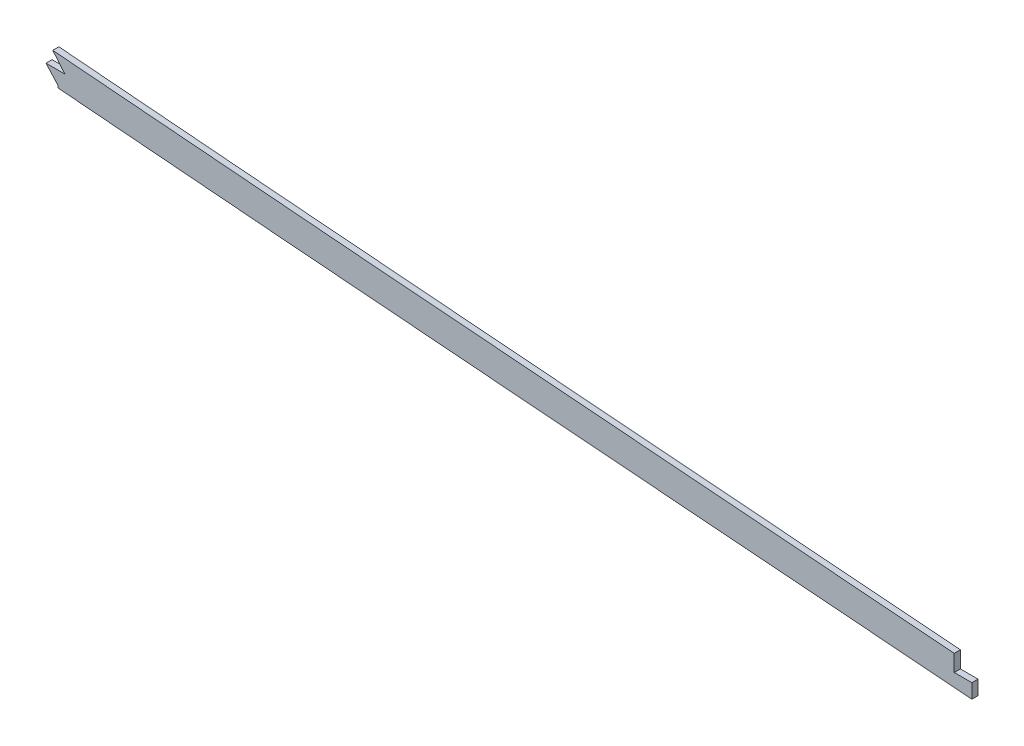
from build123d import *

# Parameters (mm, degrees)
BOSS_EXTRUDE1_DEPTH = 1.5875
FILLET1_R           = 2.54
CUT_EXTRUDE1_DEPTH  = 7.62


with BuildPart() as part:
    # Sketch2 → Boss-Extrude1 (new body, symmetric)
    with BuildSketch(Plane.XY):
        with BuildLine():
            add(Edge.make_bspline(
                [(825.5, 263.72872798), (833.004293944, 262.763036085), (840.535916247, 261.846014478), (848.126574562, 260.964164828), (892.90639318, 255.945629274), (937.686211733, 251.779150949), (973.452075064, 248.227669425), (1071.946672141, 239.051054038), (1170.441269319, 229.731506738), (1231.791940344, 224.503945813), (1324.899336146, 216.790627817), (1418.006730935, 209.040117978), (1449.742935921, 206.361809936), (1636.928606778, 190.521130342), (1824.114277635, 175.409157235), (1979.966947376, 164.299650253), (2156.268639429, 150.414433314), (2332.570330468, 133.857216402), (2354.212983157, 131.78508222), (2394.341467798, 127.847039259), (2434.469952439, 123.717187755), (2453.57670361, 121.704562273), (2472.669581058, 119.647220503), (2491.74, 117.547195763)],
                knots=[78.681340958, 78.681340958, 78.681340958, 78.681340958, 78.681340958, 78.681340958, 82.46579272, 82.46579272, 82.46579272, 100.7932901, 100.7932901, 100.7932901, 131.0989539, 131.0989539, 131.0989539, 146.7691983, 146.7691983, 146.7691983, 223.5339586, 223.5339586, 223.5339586, 233.9431167, 233.9431167, 233.9431167, 243.40815085, 243.40815085, 243.40815085, 243.40815085, 243.40815085, 243.40815085], degree=5))
            Line((825.5, 263.72872798), (825.5, 248.364439806))
            add(Edge.make_bspline(
                [(825.5, 248.364439806), (827.20768691, 248.14708351), (833.784664511, 247.321927102), (845.28106727, 245.953419483), (860.086531547, 244.295598067), (879.830703434, 242.186646028), (904.369967092, 239.698279806), (933.571022669, 236.832150625), (962.642718041, 234.023667741), (991.762593943, 231.241975908), (1021.072010315, 228.475862291), (1060.376437315, 224.796956681), (1109.513015577, 220.184378862), (1168.511190361, 214.817071985), (1227.500129793, 209.662054042), (1306.133167947, 203.021178328), (1404.361477105, 194.920725932), (1522.239851071, 184.918066624), (1640.182856491, 175.167007786), (1758.165352567, 165.757639485), (1876.155384769, 156.590937079), (1994.08749188, 147.453250142), (2092.268692061, 139.624216053), (2170.748029042, 133.079656729), (2219.771730977, 128.842227836), (2258.983988247, 125.347211495), (2288.379457536, 122.670854497), (2317.812243116, 119.931729386), (2347.551509172, 117.100365283), (2377.159899727, 114.21011853), (2406.469653851, 111.26896801), (2435.81832606, 108.240091266), (2464.242715806, 105.222889554), (2482.876892709, 103.192325927), (2491.74, 102.214848055)],
                knots=[78.875303138, 78.875303138, 78.875303138, 78.875303138, 79.386176103, 80.841530691, 82.29688528, 83.752239868, 86.662949044, 89.57365822, 92.484367397, 95.395076573, 98.305785749, 101.216494926, 107.037913278, 112.859331631, 118.680749984, 124.502168336, 136.145005042, 147.787841747, 159.430678452, 171.073515158, 182.716351863, 194.359188568, 206.002025273, 211.823443626, 217.644861979, 220.555571155, 223.466280331, 226.376989508, 229.287698684, 232.19840786, 235.109117037, 238.019826213, 240.930535389, 243.57402126, 243.57402126, 243.57402126, 243.57402126], degree=3))
            Line((2491.74, 102.214848055), (2491.74, 117.547195763))
        make_face()
    extrude(amount=BOSS_EXTRUDE1_DEPTH, both=True)

    # Fillet1
    fillet1_edges = [part.edges().sort_by_distance(p)[0] for p in [
        (2491.74, 102.214848055, -0.79375),
        (2491.74, 117.547195763, -0.79375),
        (825.5, 248.364439806, -0.79375),
        (825.5, 263.72872798, 0.79375),
    ]]
    fillet(fillet1_edges, radius=FILLET1_R)

    # Sketch3 → Cut-Extrude1 (cut)
    with BuildSketch(Plane.XY.offset(1.5875)):
        Polygon((1554.781712943, 197.53701635), (1554.781712943, 212.261982037), (810.451845726, 281.004031423), (810.451845726, 218.449722533), (1556.643823708, 177.737068235), (1557.611128436, 183.063577113), (1551.311808982, 190.02917074), (1561.124210439, 190.02917074), align=None)
        Polygon((2021.302635877, 160.549539386), (2021.302635877, 151.973195802), (2030.428965883, 151.973195802), (2030.428965883, 144.537877355), (2030.428965883, 141.701918937), (2503.989680451, 84.628223704), (2503.989680451, 125.393497308), (2021.302635877, 169.971712045), align=None)
    extrude(amount=-CUT_EXTRUDE1_DEPTH, mode=Mode.SUBTRACT)


solid = part.part
